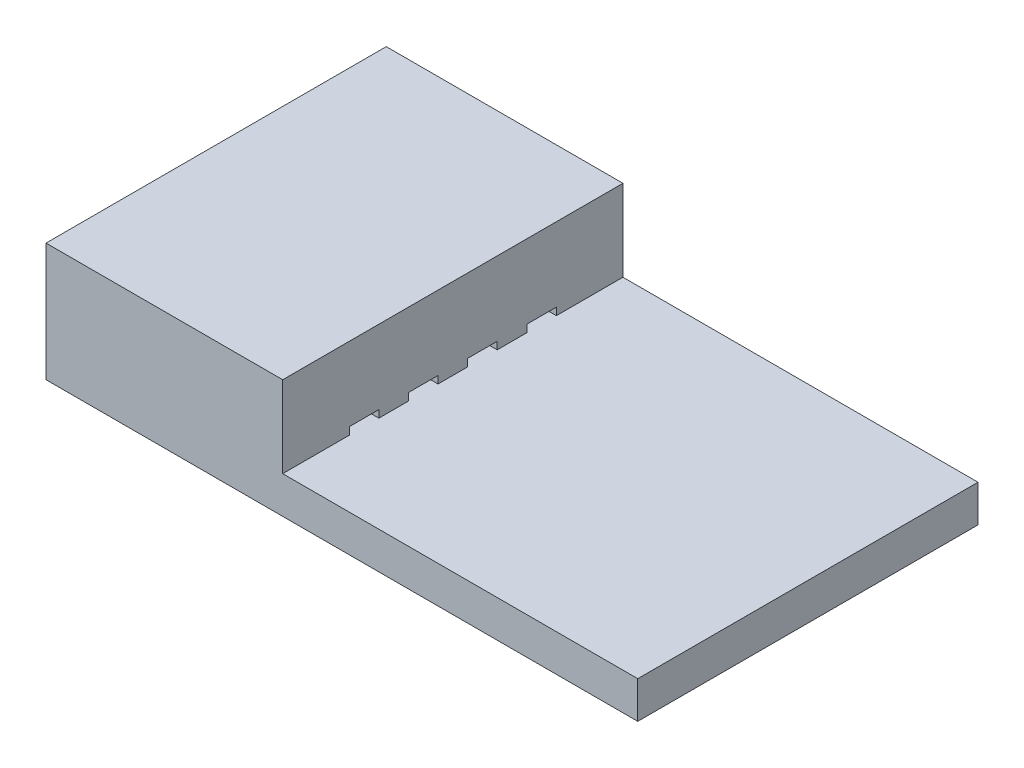
from build123d import *

# Parameters (mm, degrees)
INSULATOR_BODY_SKETCH_W    = 11.5
INSULATOR_BODY_SKETCH_H    = 4
INSULATOR_BODY_DEPTH       = 20
INSULATOR_TONGUE_SKETCH_W  = 12
INSULATOR_TONGUE_SKETCH_H  = 11.5
INSULATOR_TONGUE_DEPTH     = 2.75
CONTACT_SLOT_SKETCH_W      = 1
CONTACT_SLOT_SKETCH_H      = 0.25
CONTACT_SLOT_DEPTH         = 9
CONTACT_SLOT_PATTERN_COUNT = 4
CONTACT_SLOT_PATTERN_PITCH = 2


with BuildPart() as part:
    # Insulator_body_sketch → Insulator_body (new body)
    with BuildSketch(Plane(origin=(0, 0, 0), x_dir=(0, 0, -1), z_dir=(1, 0, 0))):
        Rectangle(INSULATOR_BODY_SKETCH_W, INSULATOR_BODY_SKETCH_H)
    extrude(amount=-INSULATOR_BODY_DEPTH)

    # Insulator_tongue_sketch → Insulator_tongue (cut)
    with BuildSketch(Plane(origin=(0, 2, 0), x_dir=(1, 0, 0), z_dir=(0, 1, 0))):
        with Locations((-6, 0)):
            Rectangle(INSULATOR_TONGUE_SKETCH_W, INSULATOR_TONGUE_SKETCH_H)
    extrude(amount=-INSULATOR_TONGUE_DEPTH, mode=Mode.SUBTRACT)

    # Contact_slot_sketch → Contact_slot (cut, through all)
    with BuildSketch(Plane(origin=(-12, 0, 0), x_dir=(0, 0, -1), z_dir=(1, 0, 0))):
        with Locations((-3, -0.625)):
            Rectangle(CONTACT_SLOT_SKETCH_W, CONTACT_SLOT_SKETCH_H)
    contact_slot = extrude(amount=-CONTACT_SLOT_DEPTH, mode=Mode.SUBTRACT)

    # Contact_slot_pattern: Contact_slot ×4
    with Locations(*[(0, 0, -i * CONTACT_SLOT_PATTERN_PITCH) for i in range(1, CONTACT_SLOT_PATTERN_COUNT)]):
        add(contact_slot, mode=Mode.SUBTRACT)


solid = part.part
